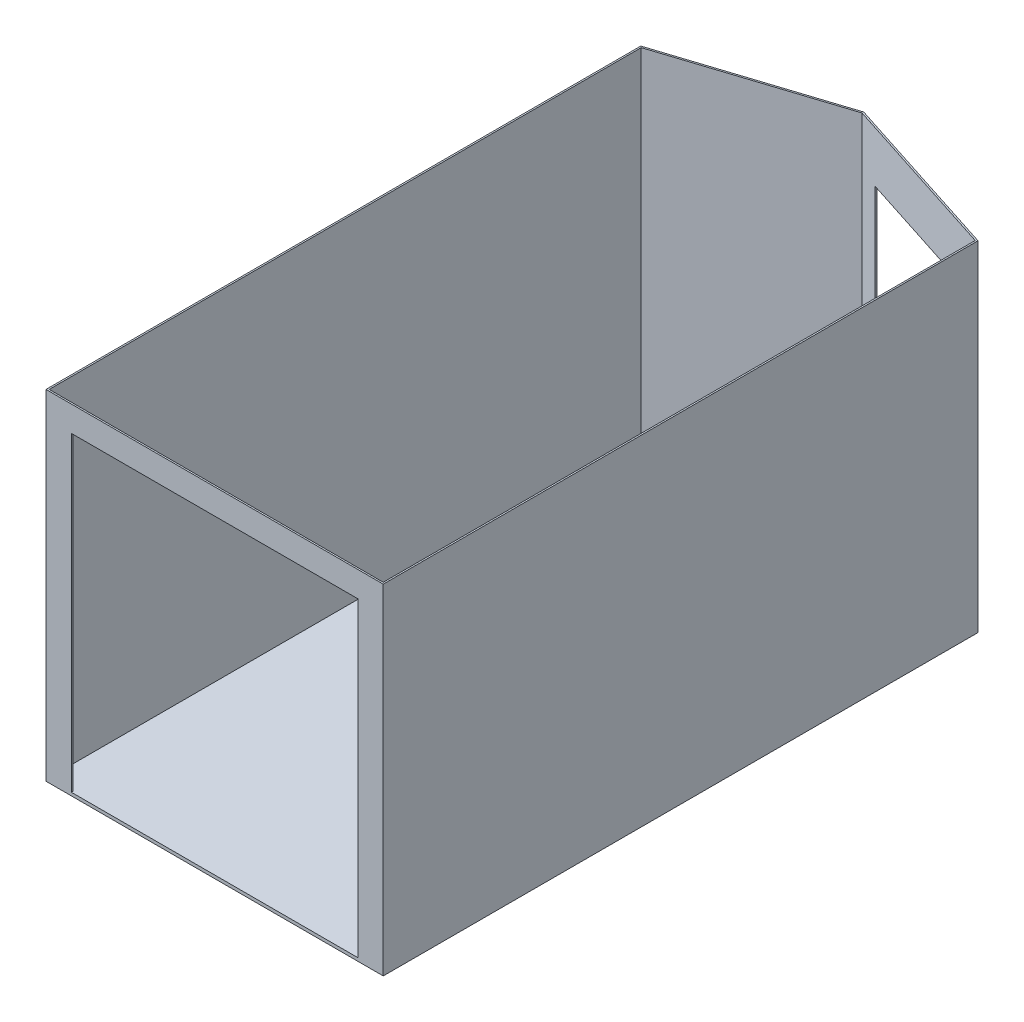
from build123d import *

# Parameters (mm, degrees)
BOSS_EXTRUDE1_DEPTH = 2019.3
BOSS_EXTRUDE2_DEPTH = 19.05
CUT_EXTRUDE1_REACH  = 4023.557
SKETCH3_W           = 812.8
SKETCH3_H           = 1714.5
CUT_EXTRUDE2_REACH  = 3900.821
SKETCH4_W           = 1720.85
SKETCH4_H           = 1866.9


with BuildPart() as part:
    # Sketch1 → Boss-Extrude1 (new body)
    with BuildSketch(Plane(origin=(0, 0, 0), x_dir=(1, 0, 0), z_dir=(0, 1, 0))):
        Polygon((-1012.825, 1784.938077022), (0, 2111.29649884), (1012.825, 1784.938077022), (1012.825, -1787.525), (-1012.825, -1787.525), align=None)
        Polygon((-1003.3, 1778), (0, 2101.289220358), (1003.3, 1778), (1003.3, -1778), (-1003.3, -1778), align=None, mode=Mode.SUBTRACT)
    extrude(amount=BOSS_EXTRUDE1_DEPTH)

    # Sketch2 → Boss-Extrude2 (add)
    with BuildSketch(Plane.XZ):
        Polygon((-1012.825, 1787.525), (-1012.825, -1784.938077022), (0, -2111.29649884), (1012.825, -1784.938077022), (1012.825, 1787.525), align=None)
    extrude(amount=BOSS_EXTRUDE2_DEPTH)

    # Sketch3 → Cut-Extrude1 (cut, up to next)
    with BuildSketch(Plane(origin=(616.321952552, 0, -1912.701618414), x_dir=(-0.951807229, 0, -0.306696917), z_dir=(0.306696917, 0, -0.951807229)), mode=Mode.PRIVATE) as cut_extrude1_sk1:
        with Locations((115.766478733, 857.25)):
            Rectangle(SKETCH3_W, SKETCH3_H)
    cut_extrude1_tool1 = extrude(cut_extrude1_sk1.sketch, amount=-CUT_EXTRUDE1_REACH, mode=Mode.PRIVATE) & part.part
    add(cut_extrude1_tool1.solids().sort_by_distance((506.134581, 857.25, -1948.206841))[0], mode=Mode.SUBTRACT)

    # Sketch4 → Cut-Extrude2 (cut, up to next)
    with BuildSketch(Plane.XY.offset(1787.525), mode=Mode.PRIVATE) as cut_extrude2_sk1:
        with Locations((0, 933.45)):
            Rectangle(SKETCH4_W, SKETCH4_H)
    cut_extrude2_tool1 = extrude(cut_extrude2_sk1.sketch, amount=-CUT_EXTRUDE2_REACH, mode=Mode.PRIVATE) & part.part
    add(cut_extrude2_tool1.solids().sort_by_distance((0, 933.45, 1787.525))[0], mode=Mode.SUBTRACT)


solid = part.part
